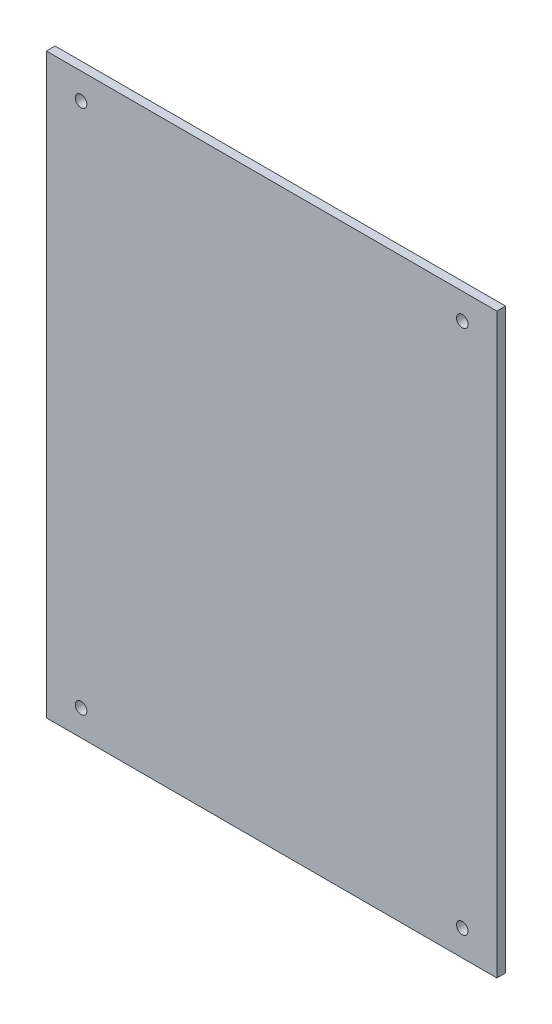
from build123d import *

# Parameters (mm, degrees)
ESQUISSE1_W             = 156
ESQUISSE1_H             = 200
BOSS_EXTRU_1_DEPTH      = 3
ESQUISSE2_R             = 2
ENL_V_MAT_EXTRU_1_DEPTH = 3


with BuildPart() as part:
    # Esquisse1 → Boss.-Extru.1 (new body)
    with BuildSketch(Plane.XY):
        with Locations((78, 100)):
            Rectangle(ESQUISSE1_W, ESQUISSE1_H)
    extrude(amount=BOSS_EXTRU_1_DEPTH)

    # Esquisse2 → Enlèv. mat.-Extru.1 (cut)
    with BuildSketch(Plane.XY.offset(3)):
        with Locations((12, 9)):
            Circle(ESQUISSE2_R)
        with Locations((144, 9)):
            Circle(ESQUISSE2_R)
        with Locations((144, 191)):
            Circle(ESQUISSE2_R)
        with Locations((12, 191)):
            Circle(ESQUISSE2_R)
    extrude(amount=-ENL_V_MAT_EXTRU_1_DEPTH, mode=Mode.SUBTRACT)


solid = part.part
